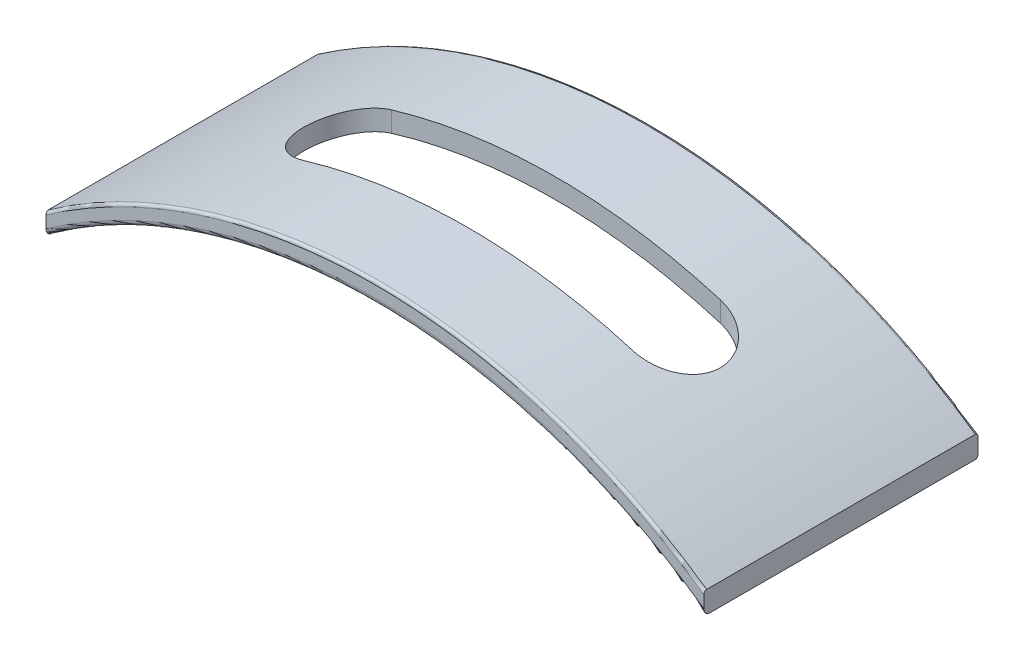
from build123d import *

# Parameters (mm, degrees)
BOSS_EXTRUDE1_DEPTH = 25
FILLET2_R           = 0.25
FILLET3_R           = 0.5
FILLET5_R           = 0.25
CUT_EXTRUDE2_DEPTH  = 10.448688931


with BuildPart() as part:
    # Sketch1 → Boss-Extrude1 (new body)
    with BuildSketch(Plane.XY):
        with BuildLine():
            Line((-30, 0), (-30, -2))
            ThreePointArc((-30, -2), (0, 7.632365953), (30, -2))
            Line((30, -2), (30, 0))
            ThreePointArc((30, 0), (0, 9.448688831), (-30, 0))
        make_face()
    extrude(amount=BOSS_EXTRUDE1_DEPTH)

    # Fillet2
    fillet2_edges = [part.edges().sort_by_distance(p)[0] for p in [
        (0, 9.448688831, 25),
    ]]
    fillet(fillet2_edges, radius=FILLET2_R)

    # Fillet3
    fillet3_edges = [part.edges().sort_by_distance(p)[0] for p in [
        (0, 7.632365953, 25),
    ]]
    fillet(fillet3_edges, radius=FILLET3_R)

    # Fillet5
    fillet5_edges = [part.edges().sort_by_distance(p)[0] for p in [
        (0, 9.448688831, 0),
        (0, 7.632365953, 0),
    ]]
    fillet(fillet5_edges, radius=FILLET5_R)

    # Sketch6 → Cut-Extrude2 (cut, through all)
    with BuildSketch(Plane(origin=(0, 0, 0), x_dir=(1, 0, 0), z_dir=(0, 1, 0))):
        with BuildLine():
            Line((-15, -8.5), (15, -8.5))
            ThreePointArc((15, -8.5), (19, -12.5), (15, -16.5))
            Line((15, -16.5), (-15, -16.5))
            ThreePointArc((-15, -16.5), (-19, -12.5), (-15, -8.5))
        make_face()
    extrude(amount=CUT_EXTRUDE2_DEPTH, mode=Mode.SUBTRACT)


solid = part.part
